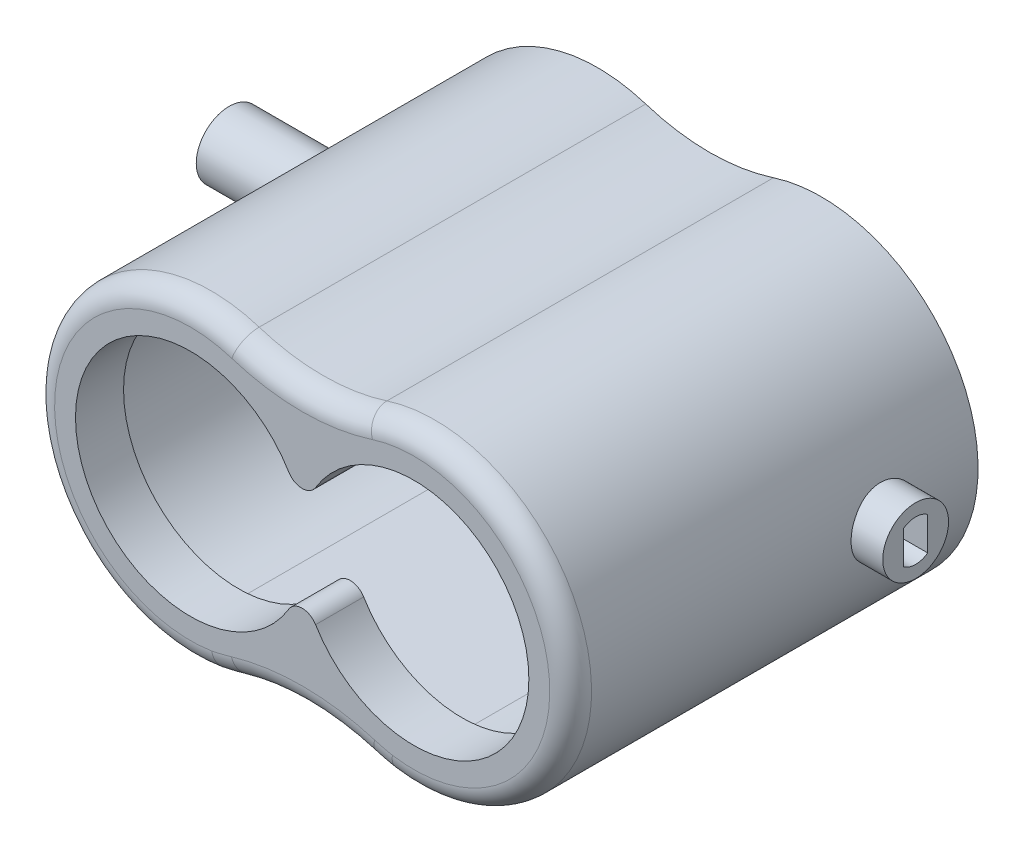
from build123d import *
from build123d.topology import SkipClean

# Parameters (mm, degrees)
BOSS_EXTRUDE1_DEPTH       = 8.89
CUT_EXTRUDE1_DEPTH        = 3.048
F_4_40_TAPPED_HOLE1_D     = 2.2606
F_4_40_TAPPED_HOLE1_DEPTH = 4.318
F_4_40_TAPPED_HOLE1_TIP   = 0.679152758
CUT_EXTRUDE2_REACH        = 74.33
SKETCH14_R                = 1.8288
CUT_EXTRUDE3_DEPTH        = 38.862
BOSS_EXTRUDE3_START       = 40.64
BOSS_EXTRUDE3_DEPTH       = 40.64
BOSS_EXTRUDE4_START       = 30.48
SKETCH20_R                = 4
BOSS_EXTRUDE4_DEPTH       = 6
BOSS_EXTRUDE5_DEPTH       = 0.508
BOSS_EXTRUDE5_DEPTH_BACK  = 6
BOSS_EXTRUDE5_START       = -30.48
SKETCH20_2_R              = 4
CUT_EXTRUDE5_START        = -55.88
SKETCH21_R                = 2.5
CUT_EXTRUDE5_DEPTH        = 24.678
CUT_EXTRUDE6_DEPTH        = 6
BOSS_EXTRUDE6_START       = -2.794
SKETCH23_R                = 4.75
SKETCH23_R_2              = 3.596259124
BOSS_EXTRUDE6_DEPTH       = 3.984
SKETCH25_R                = 4
SKETCH25_R_2              = 2.5
BOSS_EXTRUDE7_DEPTH       = 10.500000034
SKETCH27_R                = 1
CUT_EXTRUDE7_DEPTH        = 9.666
FILLET6_R                 = 2.54


with BuildPart() as part:
    # Sketch3 → Boss-Extrude1 (new body)
    with BuildSketch(Plane.XY):
        with BuildLine():
            Line((27.94, 0), (-27.94, 0))
            Line((-27.94, 0), (-27.94, 3.302))
            ThreePointArc((-27.94, 3.302), (-27.196051224, 5.098051224), (-25.4, 5.842))
            Line((-25.4, 5.842), (-9.525, 5.842))
            ThreePointArc((-9.525, 5.842), (-5.034871939, 7.701871939), (-3.175, 12.192))
            Line((-3.175, 12.192), (-3.175, 19.808714252))
            ThreePointArc((-3.175, 19.808714252), (-5.409729657, 24.644730174), (-10.541, 26.076907293))
            ThreePointArc((-10.541, 26.076907293), (-32.585448492, 46.308877289), (-7.765142857, 63.019435252))
            ThreePointArc((-7.765142857, 63.019435252), (0, 61.803367034), (7.765142857, 63.019435252))
            ThreePointArc((7.765142857, 63.019435252), (32.585448492, 46.308877289), (10.541, 26.076907293))
            ThreePointArc((10.541, 26.076907293), (5.409729657, 24.644730174), (3.175, 19.808714252))
            Line((3.175, 19.808714252), (3.175, 12.192))
            ThreePointArc((3.175, 12.192), (5.034871939, 7.701871939), (9.525, 5.842))
            Line((9.525, 5.842), (25.4, 5.842))
            ThreePointArc((25.4, 5.842), (27.196051224, 5.098051224), (27.94, 3.302))
            Line((27.94, 3.302), (27.94, 0))
        make_face()
        with BuildLine():
            ThreePointArc((-1.63068, 52.103638642), (-27.559, 44.881486416), (-1.63068, 37.65933419))
            ThreePointArc((-1.63068, 37.65933419), (0, 38.57949525), (1.63068, 37.65933419))
            ThreePointArc((1.63068, 37.65933419), (27.559, 44.881486416), (1.63068, 52.103638642))
            ThreePointArc((1.63068, 52.103638642), (0, 51.183477582), (-1.63068, 52.103638642))
        make_face(mode=Mode.SUBTRACT)
    extrude(amount=BOSS_EXTRUDE1_DEPTH)

    # Sketch5 → Cut-Extrude1 (cut)
    with BuildSketch(Plane(origin=(0, 0, 0), x_dir=(-1, 0, 0), z_dir=(0, 0, -1))):
        with BuildLine():
            Line((13.7795, 60.121486416), (-13.7795, 60.121486416))
            ThreePointArc((-13.7795, 60.121486416), (-29.0195, 44.881486416), (-13.7795, 29.641486416))
            Line((-13.7795, 29.641486416), (13.7795, 29.641486416))
            ThreePointArc((13.7795, 29.641486416), (29.0195, 44.881486416), (13.7795, 60.121486416))
        make_face()
    extrude(amount=-CUT_EXTRUDE1_DEPTH, mode=Mode.SUBTRACT)

    # 4-40 Tapped Hole1
    with Locations(Plane(origin=(0, 0, 3.048), x_dir=(-1, 0, 0), z_dir=(0, 0, -1))):
        with Locations((0, 56.057486416), (0, 33.705486416)):
            Hole(F_4_40_TAPPED_HOLE1_D / 2, depth=F_4_40_TAPPED_HOLE1_DEPTH)
            with Locations((0, 0, -(F_4_40_TAPPED_HOLE1_DEPTH + F_4_40_TAPPED_HOLE1_TIP / 2))):  # 118° drill point
                Cone(0, F_4_40_TAPPED_HOLE1_D / 2, F_4_40_TAPPED_HOLE1_TIP, mode=Mode.SUBTRACT)

    # Sketch14 → Cut-Extrude2 (cut, up to next)
    with BuildSketch(Plane(origin=(0, 0, 0), x_dir=(-1, 0, 0), z_dir=(0, -1, 0)), mode=Mode.PRIVATE) as cut_extrude2_sk1:
        with Locations((22.225, -4.445)):
            Circle(SKETCH14_R)
    cut_extrude2_tool1 = extrude(cut_extrude2_sk1.sketch, amount=-CUT_EXTRUDE2_REACH, mode=Mode.PRIVATE) & part.part
    # Sketch14 → Cut-Extrude2 (cut, up to next)
    with BuildSketch(Plane(origin=(0, 0, 0), x_dir=(-1, 0, 0), z_dir=(0, -1, 0)), mode=Mode.PRIVATE) as cut_extrude2_sk2:
        with Locations((-22.225, -4.445)):
            Circle(SKETCH14_R)
    cut_extrude2_tool2 = extrude(cut_extrude2_sk2.sketch, amount=-CUT_EXTRUDE2_REACH, mode=Mode.PRIVATE) & part.part
    add(cut_extrude2_tool1.solids().sort_by_distance((-22.225, 0, 4.445))[0], mode=Mode.SUBTRACT)
    add(cut_extrude2_tool2.solids().sort_by_distance((22.225, 0, 4.445))[0], mode=Mode.SUBTRACT)

    # Sketch15 → Cut-Extrude3 (cut)
    with BuildSketch(Plane.XY.offset(8.89)):
        with BuildLine():
            Line((-10.541, 26.076907293), (-57.74295943, 0))
            Line((-57.74295943, 0), (-18.699372608, -16.511014467))
            Line((-18.699372608, -16.511014467), (69.238576279, -8.255507234))
            Line((69.238576279, -8.255507234), (10.541, 26.076907293))
            ThreePointArc((10.541, 26.076907293), (9.304936493, 26.342971235), (8.084902933, 26.674876531))
            ThreePointArc((8.084902933, 26.674876531), (0.10450601, 27.864681788), (-7.884211813, 26.732092214))
            ThreePointArc((-7.884211813, 26.732092214), (-9.205484653, 26.375622927), (-10.541, 26.076907293))
        make_face()
    extrude(amount=-CUT_EXTRUDE3_DEPTH, mode=Mode.SUBTRACT)

    # Sketch19 → Boss-Extrude3 (add)
    with SkipClean():  # the faces are left unmerged after this step: merging them gives an invalid solid
        with BuildSketch(Plane(origin=(0, 0, 0), x_dir=(-1, 0, 0), z_dir=(0, 0, -1)).offset(BOSS_EXTRUDE3_START)):
            with BuildLine():
                ThreePointArc((-7.765142857, 63.019435252), (0, 61.803367034), (7.765142857, 63.019435252))
                ThreePointArc((7.765142857, 63.019435252), (32.585448492, 46.308877289), (10.541, 26.076907293))
                ThreePointArc((10.541, 26.076907293), (9.205484653, 26.375622927), (7.884211813, 26.732092214))
                ThreePointArc((7.884211813, 26.732092214), (-0.10450601, 27.864681788), (-8.084902933, 26.674876531))
                ThreePointArc((-8.084902933, 26.674876531), (-9.304936493, 26.342971235), (-10.541, 26.076907293))
                ThreePointArc((-10.541, 26.076907293), (-32.585448492, 46.308877289), (-7.765142857, 63.019435252))
            make_face()
            with BuildLine():
                Line((-13.7795, 29.641486416), (13.7795, 29.641486416))
                ThreePointArc((13.7795, 29.641486416), (29.0195, 44.881486416), (13.7795, 60.121486416))
                Line((13.7795, 60.121486416), (-13.7795, 60.121486416))
                ThreePointArc((-13.7795, 60.121486416), (-29.0195, 44.881486416), (-13.7795, 29.641486416))
            make_face(mode=Mode.SUBTRACT)
        extrude(amount=-BOSS_EXTRUDE3_DEPTH)

    # Sketch20_2 → Boss-Extrude5 (add, two sides: drawn at the far end of the back side and taken through both)
    with SkipClean():  # the faces are left unmerged after this step: merging them gives an invalid solid
        with BuildSketch(Plane(origin=(0, 0, 0), x_dir=(0, 0, -1), z_dir=(1, 0, 0)).offset(BOSS_EXTRUDE5_START - BOSS_EXTRUDE5_DEPTH_BACK)):
            with Locations((29.21, 44.881486416)):
                Circle(SKETCH20_2_R)
        extrude(amount=BOSS_EXTRUDE5_DEPTH + BOSS_EXTRUDE5_DEPTH_BACK)

    # Sketch21 → Cut-Extrude5 (cut)
    with SkipClean():  # the faces are left unmerged after this step: merging them gives an invalid solid
        with BuildSketch(Plane(origin=(36.48, 0, 0), x_dir=(0, 0, -1), z_dir=(1, 0, 0)).offset(CUT_EXTRUDE5_START)):
            with Locations((29.21, 44.881486416)):
                Circle(SKETCH21_R)
        extrude(amount=-CUT_EXTRUDE5_DEPTH, mode=Mode.SUBTRACT)


with BuildPart() as body_2:
    # Sketch20 → Boss-Extrude4 (new body)
    with BuildSketch(Plane(origin=(0, 0, 0), x_dir=(0, 0, -1), z_dir=(1, 0, 0)).offset(BOSS_EXTRUDE4_START)):
        with Locations((29.21, 44.881486416)):
            Circle(SKETCH20_R)
    extrude(amount=BOSS_EXTRUDE4_DEPTH)


with BuildPart() as cut_extrude6_tool:
    # Sketch22 → Cut-Extrude6 (new body)
    with SkipClean():  # the faces are left unmerged after this step: merging them gives an invalid solid
        with BuildSketch(Plane(origin=(36.48, 0, 0), x_dir=(0, 0, -1), z_dir=(1, 0, 0))):
            with BuildLine():
                Line((27.745000009, 46.90726415), (27.745000009, 42.855708683))
                ThreePointArc((27.745000009, 42.855708683), (29.21, 42.381486336), (30.674999991, 42.855708683))
                Line((30.674999991, 42.855708683), (30.674999991, 46.90726415))
                ThreePointArc((30.674999991, 46.90726415), (29.21, 47.381486496), (27.745000009, 46.90726415))
            make_face()
        extrude(amount=-CUT_EXTRUDE6_DEPTH)


with BuildPart() as part_1:
    with SkipClean():  # the faces are left unmerged after this step: merging them gives an invalid solid
        add(part.part)

        # Cut-Extrude6: cut by cut_extrude6_tool
        add(cut_extrude6_tool.part, mode=Mode.SUBTRACT)

    # Sketch23 → Boss-Extrude6 (add)
    with SkipClean():  # the faces are left unmerged after this step: merging them gives an invalid solid
        with BuildSketch(Plane.ZY.offset(36.48).offset(BOSS_EXTRUDE6_START)):
            with Locations((-29.21, 44.881486416)):
                Circle(SKETCH23_R)
            with Locations((-29.21, 44.881486416)):
                Circle(SKETCH23_R_2, mode=Mode.SUBTRACT)
        extrude(amount=-BOSS_EXTRUDE6_DEPTH)

    # Sketch25 → Boss-Extrude7 (add)
    with SkipClean():  # the faces are left unmerged after this step: merging them gives an invalid solid
        with BuildSketch(Plane.ZY.offset(36.48)):
            with Locations((-29.21, 44.881486416)):
                Circle(SKETCH25_R)
            with Locations((-29.21, 44.881486416)):
                Circle(SKETCH25_R_2, mode=Mode.SUBTRACT)
        extrude(amount=BOSS_EXTRUDE7_DEPTH)

    # Sketch27 → Cut-Extrude7 (cut)
    with SkipClean():  # the faces are left unmerged after this step: merging them gives an invalid solid
        with BuildSketch(Plane(origin=(0, 0, -40.64), x_dir=(-1, 0, 0), z_dir=(0, 0, -1))):
            with Locations((43.980000034, 44.881486416)):
                Circle(SKETCH27_R)
        extrude(amount=-CUT_EXTRUDE7_DEPTH, mode=Mode.SUBTRACT)

    # Fillet6
    fillet6_edges = [part_1.edges().sort_by_distance(p)[0] for p in [
        (-32.585448492, 46.308877289, 8.89),
        (-9.205484653, 26.375622927, 8.89),
        (9.304936493, 26.342971235, 8.89),
        (0.10450601, 27.864681788, 8.89),
        (32.585448492, 46.308877289, 8.89),
        (0, 61.803367034, 8.89),
    ]]
    fillet(fillet6_edges, radius=FILLET6_R)


with BuildPart() as body_2_1:
    with SkipClean():  # the faces are left unmerged after this step: merging them gives an invalid solid
        add(body_2.part)

        # Cut-Extrude6: cut by cut_extrude6_tool
        add(cut_extrude6_tool.part, mode=Mode.SUBTRACT)


solid = Compound([part_1.part, body_2_1.part])
